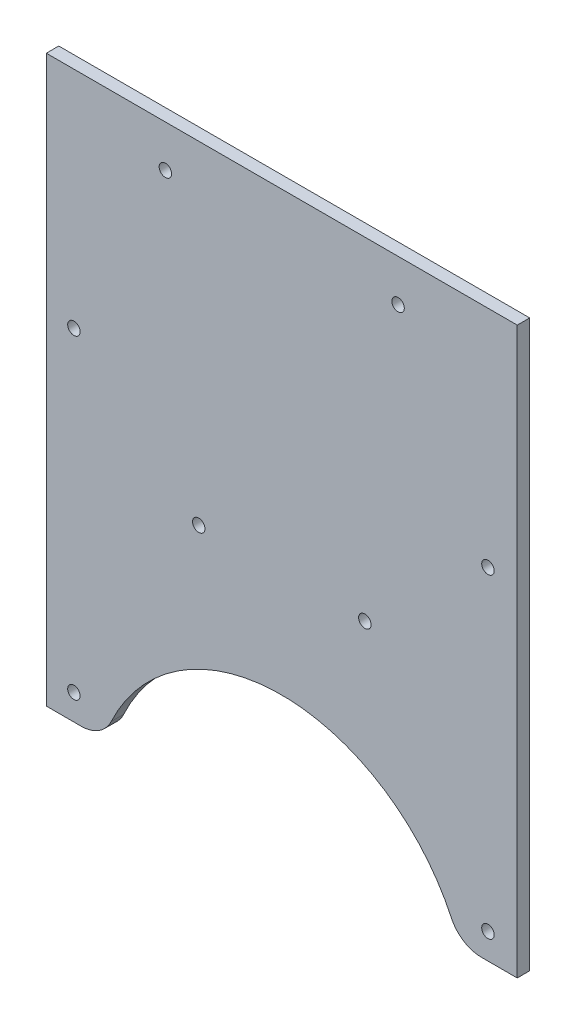
from build123d import *

# Parameters (mm, degrees)
ESQUISSE1_W             = 113.4
ESQUISSE1_H             = 180
BOSS_EXTRU_1_DEPTH      = 3
ESQUISSE2_R             = 1.5
ENL_V_MAT_EXTRU_1_DEPTH = 10
ESQUISSE3_R             = 1.5
ENL_V_MAT_EXTRU_2_DEPTH = 10
ESQUISSE5_W             = 114.090437321
ESQUISSE5_H             = 45.152715072
ENL_V_MAT_EXTRU_3_DEPTH = 10
ENL_V_MAT_EXTRU_4_DEPTH = 10
CONG_2_R                = 8


with BuildPart() as part:
    # Esquisse1 → Boss.-Extru.1 (new body)
    with BuildSketch(Plane.XY):
        with Locations((56.7, 90)):
            Rectangle(ESQUISSE1_W, ESQUISSE1_H)
    extrude(amount=BOSS_EXTRU_1_DEPTH)

    # Esquisse2 → Enlèv. mat.-Extru.1 (cut)
    with BuildSketch(Plane.XY.offset(3)):
        with Locations((106.346648171, 50.037457394)):
            Circle(ESQUISSE2_R)
        with Locations((6.647370572, 50.037457394)):
            Circle(ESQUISSE2_R)
        with Locations((6.647370572, 125.962542606)):
            Circle(ESQUISSE2_R)
        with Locations((106.346648171, 125.962542606)):
            Circle(ESQUISSE2_R)
    extrude(amount=-ENL_V_MAT_EXTRU_1_DEPTH, mode=Mode.SUBTRACT)

    # Esquisse3 → Enlèv. mat.-Extru.2 (cut)
    with BuildSketch(Plane.XY.offset(3)):
        with Locations((76.706231896, 99.916374803)):
            Circle(ESQUISSE3_R)
        with Locations((36.706231896, 99.916374803)):
            Circle(ESQUISSE3_R)
        with Locations((84.706231896, 169.916374803)):
            Circle(ESQUISSE3_R)
        with Locations((28.675912775, 169.916374803)):
            Circle(ESQUISSE3_R)
    extrude(amount=-ENL_V_MAT_EXTRU_2_DEPTH, mode=Mode.SUBTRACT)

    # Esquisse5 → Enlèv. mat.-Extru.3 (cut)
    with BuildSketch(Plane.XY.offset(3)):
        with Locations((56.35478134, 21.269970053)):
            Rectangle(ESQUISSE5_W, ESQUISSE5_H)
    extrude(amount=-ENL_V_MAT_EXTRU_3_DEPTH, mode=Mode.SUBTRACT)

    # Esquisse6 → Enlèv. mat.-Extru.4 (cut)
    with BuildSketch(Plane.XY.offset(3)):
        with BuildLine():
            Line((99.394396977, 43.846327589), (13.780181086, 43.846327589))
            ThreePointArc((13.780181086, 43.846327589), (56.587289031, 74.506937859), (99.394396977, 43.846327589))
        make_face()
    extrude(amount=-ENL_V_MAT_EXTRU_4_DEPTH, mode=Mode.SUBTRACT)

    # Congé2
    cong_2_edges = [part.edges().sort_by_distance(p)[0] for p in [
        (99.394396977, 43.846327589, 1.5),
        (13.780181086, 43.846327589, 1.5),
    ]]
    fillet(cong_2_edges, radius=CONG_2_R)


solid = part.part
